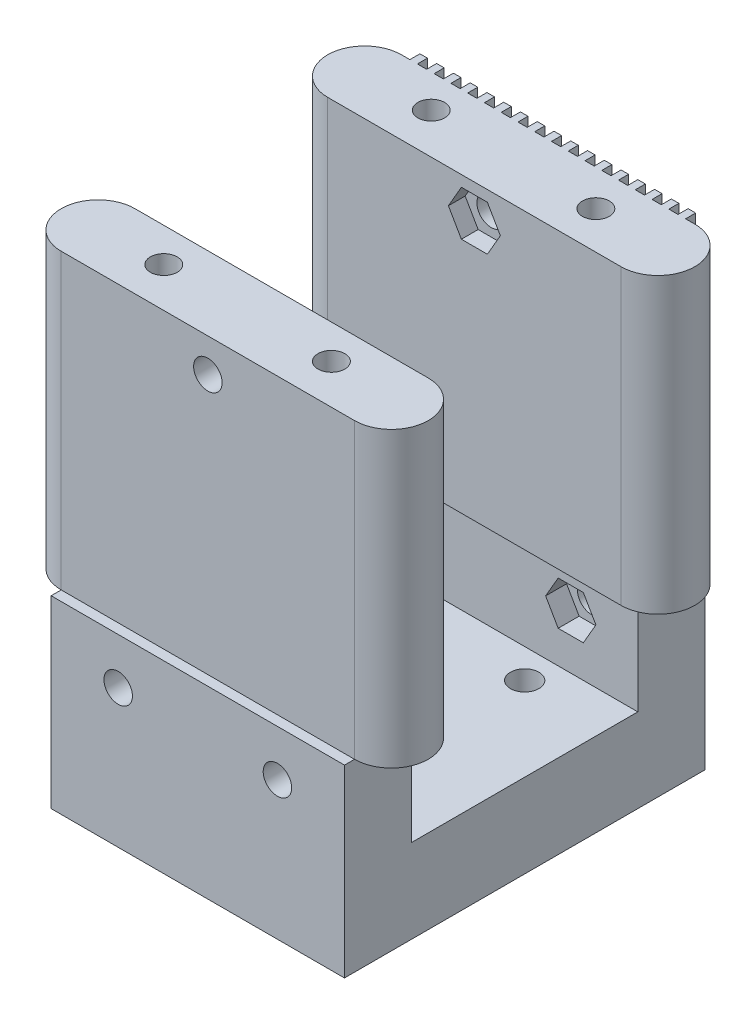
from build123d import *

# Parameters (mm, degrees)
SKETCH11_W          = 35
SKETCH11_H          = 27
BOSS_EXTRUDE6_DEPTH = 10
SKETCH12_R          = 1.7
CUT_EXTRUDE3_DEPTH  = 11
SKETCH13_W          = 35
SKETCH13_H          = 8
BOSS_EXTRUDE7_DEPTH = 22
SKETCH14_W          = 35
SKETCH14_H          = 10
BOSS_EXTRUDE8_DEPTH = 35
SKETCH17_W          = 35
SKETCH17_H          = 35
CUT_EXTRUDE6_DEPTH  = 1.2
SKETCH18_W          = 1.1
SKETCH18_H          = 35
CUT_EXTRUDE7_DEPTH  = 1.2
SKETCH19_R          = 1.7
CUT_EXTRUDE8_DEPTH  = 44
CUT_EXTRUDE9_DEPTH  = 2.5
CUT_EXTRUDE10_DEPTH = 2.5
BOSS_EXTRUDE9_DEPTH = 35
SKETCH23_R          = 1.6
CUT_EXTRUDE11_DEPTH = 15
CUT_EXTRUDE12_DEPTH = 2
CUT_EXTRUDE13_DEPTH = 2


with BuildPart() as part:
    # Sketch11 → Boss-Extrude6 (new body)
    with BuildSketch(Plane(origin=(0, 0, 12.5), x_dir=(1, 0, 0), z_dir=(0, -1, 0))):
        with Locations((17.5, -13.5)):
            Rectangle(SKETCH11_W, SKETCH11_H)
    extrude(amount=BOSS_EXTRUDE6_DEPTH)

    # Sketch12 → Cut-Extrude3 (cut, through all)
    with BuildSketch(Plane.XZ.offset(10)):
        with Locations((10, 9)):
            Circle(SKETCH12_R)
        with Locations((25, 9)):
            Circle(SKETCH12_R)
        with Locations((25, -11)):
            Circle(SKETCH12_R)
        with Locations((10, -11)):
            Circle(SKETCH12_R)
    extrude(amount=-CUT_EXTRUDE3_DEPTH, mode=Mode.SUBTRACT)

    # Sketch13 → Boss-Extrude7 (add)
    with BuildSketch(Plane.XZ.offset(10)):
        with Locations((17.5, -18.5)):
            Rectangle(SKETCH13_W, SKETCH13_H)
        with Locations((17.5, 16.5)):
            Rectangle(SKETCH13_W, SKETCH13_H)
    extrude(amount=-BOSS_EXTRUDE7_DEPTH)

    # Sketch14 → Boss-Extrude8 (add)
    with BuildSketch(Plane(origin=(0, 12, 0), x_dir=(1, 0, 0), z_dir=(0, 1, 0))):
        with Locations((17.5, -15.5)):
            Rectangle(SKETCH14_W, SKETCH14_H)
        with Locations((17.5, 17.5)):
            Rectangle(SKETCH14_W, SKETCH14_H)
    extrude(amount=BOSS_EXTRUDE8_DEPTH)

    # Sketch17 → Cut-Extrude6 (cut)
    with BuildSketch(Plane.XY.offset(20.5)):
        with Locations((17.5, 29.5)):
            Rectangle(SKETCH17_W, SKETCH17_H)
    extrude(amount=-CUT_EXTRUDE6_DEPTH, mode=Mode.SUBTRACT)

    # Sketch18 → Cut-Extrude7 (cut)
    with BuildSketch(Plane(origin=(0, 0, -22.5), x_dir=(-1, 0, 0), z_dir=(0, 0, -1))):
        with Locations((-32.45, 29.5)):
            Rectangle(SKETCH18_W, SKETCH18_H)
        with Locations((-34.45, 29.5)):
            Rectangle(SKETCH18_W, SKETCH18_H)
        with Locations((-30.45, 29.5)):
            Rectangle(SKETCH18_W, SKETCH18_H)
        with Locations((-28.45, 29.5)):
            Rectangle(SKETCH18_W, SKETCH18_H)
        with Locations((-26.45, 29.5)):
            Rectangle(SKETCH18_W, SKETCH18_H)
        with Locations((-24.45, 29.5)):
            Rectangle(SKETCH18_W, SKETCH18_H)
        with Locations((-22.45, 29.5)):
            Rectangle(SKETCH18_W, SKETCH18_H)
        with Locations((-20.45, 29.5)):
            Rectangle(SKETCH18_W, SKETCH18_H)
        with Locations((-18.45, 29.5)):
            Rectangle(SKETCH18_W, SKETCH18_H)
        with Locations((-16.45, 29.5)):
            Rectangle(SKETCH18_W, SKETCH18_H)
        with Locations((-14.45, 29.5)):
            Rectangle(SKETCH18_W, SKETCH18_H)
        with Locations((-12.45, 29.5)):
            Rectangle(SKETCH18_W, SKETCH18_H)
        with Locations((-10.45, 29.5)):
            Rectangle(SKETCH18_W, SKETCH18_H)
        with Locations((-8.45, 29.5)):
            Rectangle(SKETCH18_W, SKETCH18_H)
        with Locations((-6.45, 29.5)):
            Rectangle(SKETCH18_W, SKETCH18_H)
        with Locations((-4.45, 29.5)):
            Rectangle(SKETCH18_W, SKETCH18_H)
        with Locations((-2.45, 29.5)):
            Rectangle(SKETCH18_W, SKETCH18_H)
        with Locations((-0.45, 29.5)):
            Rectangle(SKETCH18_W, SKETCH18_H)
    extrude(amount=-CUT_EXTRUDE7_DEPTH, mode=Mode.SUBTRACT)

    # Sketch19 → Cut-Extrude8 (cut, through all)
    with BuildSketch(Plane(origin=(0, 0, -22.5), x_dir=(-1, 0, 0), z_dir=(0, 0, -1))):
        with Locations((-27, 6.485099569)):
            Circle(SKETCH19_R)
        with Locations((-8, 6.485099569)):
            Circle(SKETCH19_R)
        with Locations((-17.5, 43)):
            Circle(SKETCH19_R)
    extrude(amount=-CUT_EXTRUDE8_DEPTH, mode=Mode.SUBTRACT)

    # Sketch20 → Cut-Extrude9 (cut)
    with BuildSketch(Plane.XY.offset(-14.5)):
        Polygon((28.5, 3.887023357), (30, 6.485099569), (28.5, 9.08317578), (25.5, 9.08317578), (24, 6.485099569), (25.5, 3.887023357), align=None)
        Polygon((9.5, 3.887023357), (11, 6.485099569), (9.5, 9.08317578), (6.5, 9.08317578), (5, 6.485099569), (6.5, 3.887023357), align=None)
    extrude(amount=-CUT_EXTRUDE9_DEPTH, mode=Mode.SUBTRACT)

    # Sketch21 → Cut-Extrude10 (cut)
    with BuildSketch(Plane(origin=(0, 0, 12.5), x_dir=(-1, 0, 0), z_dir=(0, 0, -1))):
        Polygon((-6.45, 3.800420817), (-4.9, 6.485099569), (-6.45, 9.16977832), (-9.55, 9.16977832), (-11.1, 6.485099569), (-9.55, 3.800420817), align=None)
        Polygon((-25.45, 3.800420817), (-23.9, 6.485099569), (-25.45, 9.16977832), (-28.55, 9.16977832), (-30.1, 6.485099569), (-28.55, 3.800420817), align=None)
    extrude(amount=-CUT_EXTRUDE10_DEPTH, mode=Mode.SUBTRACT)

    # Sketch22 → Boss-Extrude9 (add)
    with BuildSketch(Plane(origin=(0, 47, 0), x_dir=(1, 0, 0), z_dir=(0, 1, 0))):
        with BuildLine():
            Line((35, 21.3), (35, 12.5))
            ThreePointArc((35, 12.5), (39.4, 16.9), (35, 21.3))
        make_face()
        with BuildLine():
            Line((35, -10.5), (35, -19.3))
            ThreePointArc((35, -19.3), (39.4, -14.9), (35, -10.5))
        make_face()
        with BuildLine():
            Line((0, 21.3), (0, 12.5))
            ThreePointArc((0, 12.5), (-4.4, 16.9), (0, 21.3))
        make_face()
        with BuildLine():
            Line((0, -10.5), (0, -19.3))
            ThreePointArc((0, -19.3), (-4.4, -14.9), (0, -10.5))
        make_face()
    extrude(amount=-BOSS_EXTRUDE9_DEPTH)

    # Sketch23 → Cut-Extrude11 (cut)
    with BuildSketch(Plane(origin=(0, 47, 0), x_dir=(1, 0, 0), z_dir=(0, 1, 0))):
        with Locations((7.5, 17.352667036)):
            Circle(SKETCH23_R)
        with Locations((27.5, 16.995008076)):
            Circle(SKETCH23_R)
        with Locations((27.5, -14.559659808)):
            Circle(SKETCH23_R)
        with Locations((7.5, -14.559659808)):
            Circle(SKETCH23_R)
    extrude(amount=-CUT_EXTRUDE11_DEPTH, mode=Mode.SUBTRACT)

    # Sketch24 → Cut-Extrude12 (cut)
    with BuildSketch(Plane(origin=(0, 0, 10.5), x_dir=(-1, 0, 0), z_dir=(0, 0, -1))):
        Polygon((-15.95, 40.315321248), (-14.4, 43), (-15.95, 45.684678752), (-19.05, 45.684678752), (-20.6, 43), (-19.05, 40.315321248), align=None)
    extrude(amount=-CUT_EXTRUDE12_DEPTH, mode=Mode.SUBTRACT)

    # Sketch25 → Cut-Extrude13 (cut)
    with BuildSketch(Plane.XY.offset(-12.5)):
        Polygon((19.05, 40.315321248), (20.6, 43), (19.05, 45.684678752), (15.95, 45.684678752), (14.4, 43), (15.95, 40.315321248), align=None)
    extrude(amount=-CUT_EXTRUDE13_DEPTH, mode=Mode.SUBTRACT)


solid = part.part
